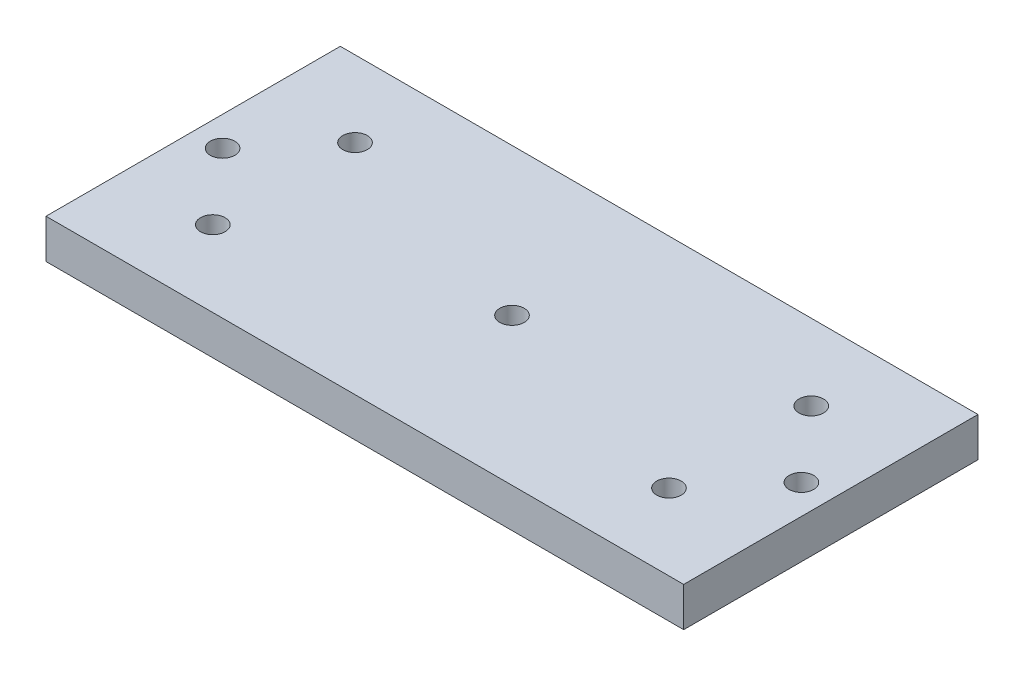
from build123d import *

# Parameters (mm, degrees)
SKETCH_1_W          = 130
SKETCH_1_H          = 60
EXTRUDE_1_DEPTH     = 8
SKETCH_2_R          = 2.5
CUT_EXTRUDE_1_DEPTH = 9


with BuildPart() as part:
    # ｽｹｯﾁ1 → ﾎﾞｽ - 押し出し1 (new body)
    with BuildSketch(Plane(origin=(0, 0, 0), x_dir=(1, 0, 0), z_dir=(0, 1, 0))):
        Rectangle(SKETCH_1_W, SKETCH_1_H)
    extrude(amount=EXTRUDE_1_DEPTH)

    # ｽｹｯﾁ2 → ｶｯﾄ - 押し出し1 (cut, through all)
    with BuildSketch(Plane(origin=(0, 8, 0), x_dir=(1, 0, 0), z_dir=(0, 1, 0))):
        Circle(SKETCH_2_R)
        with Locations((59, 0)):
            Circle(SKETCH_2_R)
        with Locations((46.5, -14.5)):
            Circle(SKETCH_2_R)
        with Locations((46.5, 14.5)):
            Circle(SKETCH_2_R)
        with Locations((-46.5, -14.5)):
            Circle(SKETCH_2_R)
        with Locations((-59, 0)):
            Circle(SKETCH_2_R)
        with Locations((-46.5, 14.5)):
            Circle(SKETCH_2_R)
    extrude(amount=-CUT_EXTRUDE_1_DEPTH, mode=Mode.SUBTRACT)


solid = part.part
